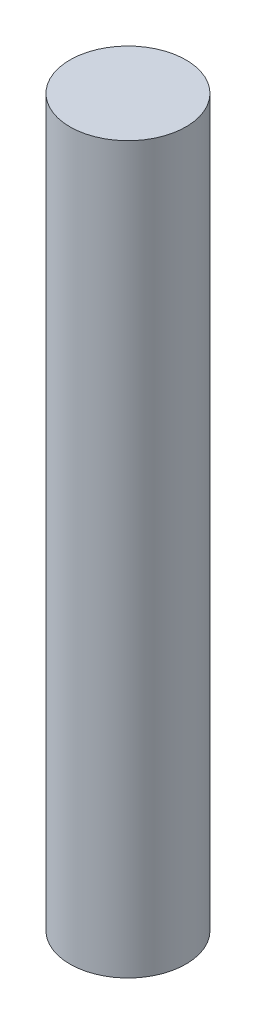
from build123d import *

# Parameters (mm, degrees)
SKETCH_3_R      = 4
EXTRUDE_2_DEPTH = 50


with BuildPart() as part:
    # 草图3 → 凸台-拉伸2 (new body)
    with BuildSketch(Plane(origin=(0, 0, 0), x_dir=(1, 0, 0), z_dir=(0, 1, 0))):
        Circle(SKETCH_3_R)
    extrude(amount=EXTRUDE_2_DEPTH)


solid = part.part
